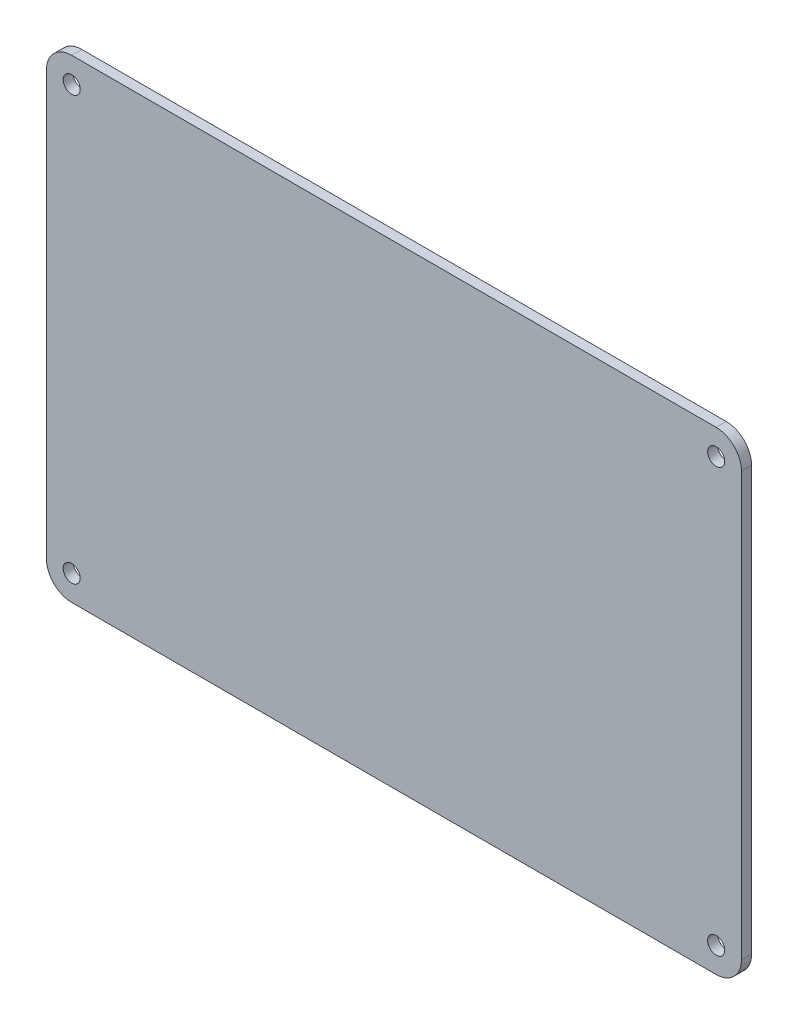
from build123d import *

# Parameters (mm, degrees)
SKETCH1_R           = 1.35
BOSS_EXTRUDE1_DEPTH = 1.6


with BuildPart() as part:
    # Sketch1 → Boss-Extrude1 (new body)
    with BuildSketch(Plane.XY):
        with BuildLine():
            Line((-51, -37.5), (51, -37.5))
            ThreePointArc((51, -37.5), (53.828427125, -36.328427125), (55, -33.5))
            Line((55, -33.5), (55, 33.5))
            ThreePointArc((55, 33.5), (53.828427125, 36.328427125), (51, 37.5))
            Line((51, 37.5), (-51, 37.5))
            ThreePointArc((-51, 37.5), (-53.828427125, 36.328427125), (-55, 33.5))
            Line((-55, 33.5), (-55, -33.5))
            ThreePointArc((-55, -33.5), (-53.828427125, -36.328427125), (-51, -37.5))
        make_face()
        with Locations((-51, 33.5)):
            Circle(SKETCH1_R, mode=Mode.SUBTRACT)
        with Locations((51, 33.5)):
            Circle(SKETCH1_R, mode=Mode.SUBTRACT)
        with Locations((51, -33.5)):
            Circle(SKETCH1_R, mode=Mode.SUBTRACT)
        with Locations((-51, -33.5)):
            Circle(SKETCH1_R, mode=Mode.SUBTRACT)
    extrude(amount=BOSS_EXTRUDE1_DEPTH)


solid = part.part
